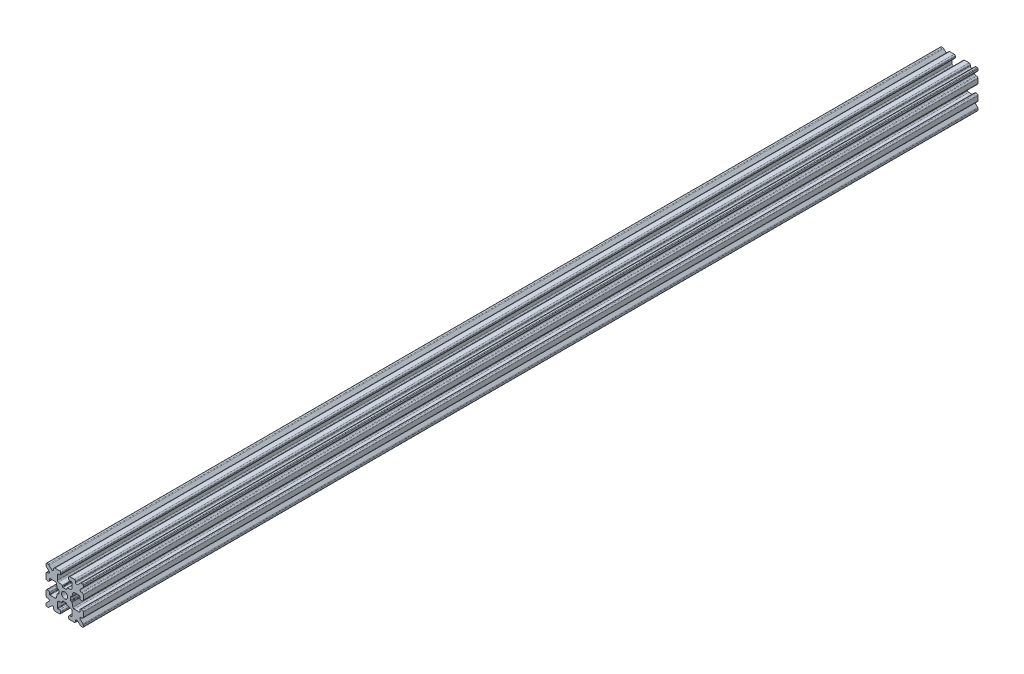
from build123d import *

# Parameters (mm, degrees)
SKETCH1_W           = 15
SKETCH1_H           = 15
SKETCH1_R           = 1.25
BOSS_EXTRUDE1_DEPTH = 180
FILLET1_R           = 0.25
CUT_EXTRUDE1_DEPTH  = 361
CUT_EXTRUDE3_DEPTH  = 361
FILLET3_R           = 0.5
FILLET4_R           = 0.5
FILLET5_R           = 3
FILLET6_R           = 0.2
CUT_EXTRUDE4_DEPTH  = 361
FILLET8_R           = 0.5
SKETCH6_W           = 5.1529354
SKETCH6_H           = 1.651
SKETCH6_W_2         = 1.651
SKETCH6_H_2         = 5.1529354
CUT_EXTRUDE5_DEPTH  = 361
FILLET10_R          = 0.2


with BuildPart() as part:
    # Sketch1 → Boss-Extrude1 (new body, symmetric)
    with BuildSketch(Plane.XY):
        Rectangle(SKETCH1_W, SKETCH1_H)
        Circle(SKETCH1_R, mode=Mode.SUBTRACT)
    extrude(amount=BOSS_EXTRUDE1_DEPTH, both=True)

    # Fillet1
    fillet1_edges = [part.edges().sort_by_distance(p)[0] for p in [
        (7.5, -7.5, 0),
        (-7.5, -7.5, 0),
        (-7.5, 7.5, 0),
        (7.5, 7.5, 0),
    ]]
    fillet(fillet1_edges, radius=FILLET1_R)

    # Sketch2 → Cut-Extrude1 (cut, through all)
    with BuildSketch(Plane.XY.offset(180)):
        Polygon((-7.5, 1.6), (-6.1, 1.6), (-6.1, 2.9), (-3.4, 2.9), (-3.4, -2.9), (-6.1, -2.9), (-6.1, -1.6), (-7.5, -1.6), align=None)
        Polygon((2.9, 6.1), (1.6, 6.1), (1.6, 7.5), (-1.6, 7.5), (-1.6, 6.1), (-2.9, 6.1), (-2.9, 3.4), (2.9, 3.4), align=None)
        Polygon((-1.6, -7.5), (-1.6, -6.1), (-2.9, -6.1), (-2.9, -3.4), (2.9, -3.4), (2.9, -6.1), (1.6, -6.1), (1.6, -7.5), align=None)
        Polygon((6.1, -2.9), (6.1, -1.6), (7.5, -1.6), (7.5, 1.6), (6.1, 1.6), (6.1, 2.9), (3.4, 2.9), (3.4, -2.9), align=None)
    extrude(amount=-CUT_EXTRUDE1_DEPTH, mode=Mode.SUBTRACT)

    # Sketch4 → Cut-Extrude3 (cut, through all)
    with BuildSketch(Plane.XY.offset(180)):
        Polygon((-3.4, 2.9), (-2.75, 0), (-3.4, -2.9), align=None)
        Polygon((-2.9, 3.4), (0, 2.75), (2.9, 3.4), align=None)
        Polygon((3.4, 2.9), (2.75, 0), (3.4, -2.9), align=None)
        Polygon((-2.9, -3.4), (0, -2.75), (2.9, -3.4), align=None)
    extrude(amount=-CUT_EXTRUDE3_DEPTH, mode=Mode.SUBTRACT)

    # Fillet3
    fillet3_edges = [part.edges().sort_by_distance(p)[0] for p in [
        (1.6, -7.5, 0),
        (-1.6, -7.5, 0),
        (-1.6, -6.1, 0),
        (1.6, -6.1, 0),
        (6.1, 1.6, 0),
        (7.5, 1.6, 0),
        (7.5, -1.6, 0),
        (6.1, -1.6, 0),
        (-7.5, -1.6, 0),
        (-7.5, 1.6, 0),
        (-6.1, 1.6, 0),
        (-6.1, -1.6, 0),
        (-1.6, 6.1, 0),
        (-1.6, 7.5, 0),
        (1.6, 7.5, 0),
        (1.6, 6.1, 0),
    ]]
    fillet(fillet3_edges, radius=FILLET3_R)

    # Fillet4
    fillet4_edges = [part.edges().sort_by_distance(p)[0] for p in [
        (-2.9, -3.4, 0),
        (2.9, -3.4, 0),
        (3.4, -2.9, 0),
        (3.4, 2.9, 0),
        (-3.4, 2.9, 0),
        (-3.4, -2.9, 0),
        (2.9, 3.4, 0),
        (-2.9, 3.4, 0),
    ]]
    fillet(fillet4_edges, radius=FILLET4_R)

    # Fillet5
    fillet5_edges = [part.edges().sort_by_distance(p)[0] for p in [
        (-2.75, 0, 0),
        (0, 2.75, 0),
        (2.75, 0, 0),
        (0, -2.75, 0),
    ]]
    fillet(fillet5_edges, radius=FILLET5_R)

    # Fillet6
    fillet6_edges = [part.edges().sort_by_distance(p)[0] for p in [
        (-2.9, -6.1, 0),
        (2.9, -6.1, 0),
        (6.1, -2.9, 0),
        (6.1, 2.9, 0),
        (-6.1, 2.9, 0),
        (-6.1, -2.9, 0),
        (2.9, 6.1, 0),
        (-2.9, 6.1, 0),
    ]]
    fillet(fillet6_edges, radius=FILLET6_R)

    # Sketch5 → Cut-Extrude4 (cut, through all)
    with BuildSketch(Plane.XY.offset(180)):
        Polygon((-7.5, 6.439339828), (-5.460660172, 4.4), (-7.5, 4.4), align=None)
        Polygon((-6.439339828, 7.5), (-4.4, 5.460660172), (-4.4, 7.5), align=None)
        Polygon((4.4, 7.5), (6.439339828, 7.5), (4.4, 5.460660172), align=None)
        Polygon((7.5, 6.439339828), (7.5, 4.4), (5.460660172, 4.4), align=None)
        Polygon((7.5, -6.439339828), (5.460660172, -4.4), (7.5, -4.4), align=None)
        Polygon((6.439339828, -7.5), (4.4, -5.460660172), (4.4, -7.5), align=None)
        Polygon((-4.4, -7.5), (-6.439339828, -7.5), (-4.4, -5.460660172), align=None)
        Polygon((-7.5, -6.439339828), (-7.5, -4.4), (-5.460660172, -4.4), align=None)
    extrude(amount=-CUT_EXTRUDE4_DEPTH, mode=Mode.SUBTRACT)

    # Fillet8
    fillet8_edges = [part.edges().sort_by_distance(p)[0] for p in [
        (-7.5, 4.4, 0),
        (-7.5, 6.439339828, 0),
        (-5.460660172, 4.4, 0),
        (7.5, -4.4, 0),
        (7.5, -6.439339828, 0),
        (5.460660172, -4.4, 0),
        (5.460660172, 4.4, 0),
        (7.5, 6.439339828, 0),
        (7.5, 4.4, 0),
        (-4.4, 7.5, 0),
        (-4.4, 5.460660172, 0),
        (-6.439339828, 7.5, 0),
        (-5.460660172, -4.4, 0),
        (-7.5, -6.439339828, 0),
        (-7.5, -4.4, 0),
        (4.4, 5.460660172, 0),
        (4.4, 7.5, 0),
        (6.439339828, 7.5, 0),
        (6.439339828, -7.5, 0),
        (4.4, -7.5, 0),
        (4.4, -5.460660172, 0),
        (-6.439339828, -7.5, 0),
        (-4.4, -5.460660172, 0),
        (-4.4, -7.5, 0),
    ]]
    fillet(fillet8_edges, radius=FILLET8_R)

    # Sketch6 → Cut-Extrude5 (cut, through all)
    with BuildSketch(Plane.XY.offset(180)):
        with Locations((4.9235323, 0)):
            Rectangle(SKETCH6_W, SKETCH6_H)
        with Locations((0, -4.9235323)):
            Rectangle(SKETCH6_W_2, SKETCH6_H_2)
        with Locations((-4.9235323, 0)):
            Rectangle(SKETCH6_W, SKETCH6_H)
        with Locations((0, 4.9235323)):
            Rectangle(SKETCH6_W_2, SKETCH6_H_2)
    extrude(amount=-CUT_EXTRUDE5_DEPTH, mode=Mode.SUBTRACT)

    # Fillet10
    fillet10_edges = [part.edges().sort_by_distance(p)[0] for p in [
        (0.8255, -2.935025862, 0),
        (-0.8255, -2.935025862, 0),
        (0.8255, -2.3470646, 0),
        (-0.8255, -2.3470646, 0),
        (2.935025862, 0.8255, 0),
        (2.935025862, -0.8255, 0),
        (2.3470646, 0.8255, 0),
        (2.3470646, -0.8255, 0),
        (-2.935025862, -0.8255, 0),
        (-2.935025862, 0.8255, 0),
        (-2.3470646, -0.8255, 0),
        (-2.3470646, 0.8255, 0),
        (-0.8255, 2.935025862, 0),
        (0.8255, 2.935025862, 0),
        (-0.8255, 2.3470646, 0),
        (0.8255, 2.3470646, 0),
    ]]
    fillet(fillet10_edges, radius=FILLET10_R)


solid = part.part
